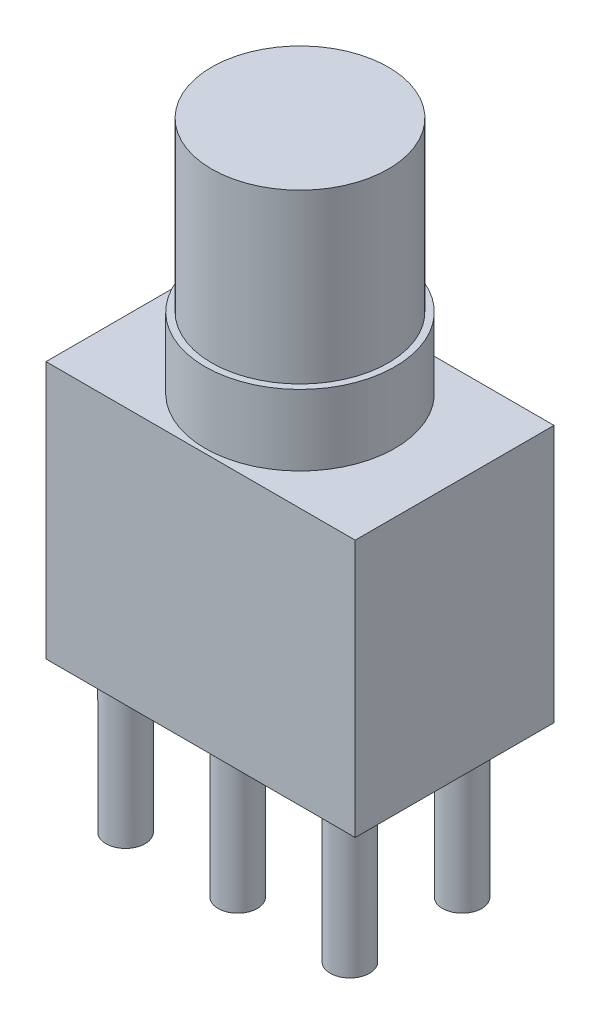
from build123d import *

# Parameters (mm, degrees)
SKETCH1_W           = 7
SKETCH1_H           = 4.5
BOSS_EXTRUDE1_DEPTH = 5.83
SKETCH2_R           = 2.15
BOSS_EXTRUDE2_DEPTH = 1.6
SKETCH3_R           = 2
BOSS_EXTRUDE3_DEPTH = 3.8
SKETCH4_R           = 0.445
BOSS_EXTRUDE4_DEPTH = 3.3


with BuildPart() as part:
    # Sketch1 → Boss-Extrude1 (new body)
    with BuildSketch(Plane(origin=(0, 0, 0), x_dir=(1, 0, 0), z_dir=(0, 1, 0))):
        with Locations((3.5, -2.25)):
            Rectangle(SKETCH1_W, SKETCH1_H)
    extrude(amount=BOSS_EXTRUDE1_DEPTH)

    # Sketch2 → Boss-Extrude2 (add)
    with BuildSketch(Plane(origin=(0, 5.83, 0), x_dir=(1, 0, 0), z_dir=(0, 1, 0))):
        with Locations((3.5, -2.25)):
            Circle(SKETCH2_R)
    extrude(amount=BOSS_EXTRUDE2_DEPTH)

    # Sketch3 → Boss-Extrude3 (add)
    with BuildSketch(Plane(origin=(0, 7.43, 0), x_dir=(1, 0, 0), z_dir=(0, 1, 0))):
        with Locations((3.5, -2.25)):
            Circle(SKETCH3_R)
    extrude(amount=BOSS_EXTRUDE3_DEPTH)

    # Sketch4 → Boss-Extrude4 (add)
    with BuildSketch(Plane.XZ):
        with Locations((1, 3.7)):
            Circle(SKETCH4_R)
        with Locations((3.54, 3.7)):
            Circle(SKETCH4_R)
        with Locations((6.08, 3.7)):
            Circle(SKETCH4_R)
        with Locations((6.08, 1.16)):
            Circle(SKETCH4_R)
        with Locations((3.54, 1.16)):
            Circle(SKETCH4_R)
        with Locations((1, 1.16)):
            Circle(SKETCH4_R)
    extrude(amount=BOSS_EXTRUDE4_DEPTH)


solid = part.part
